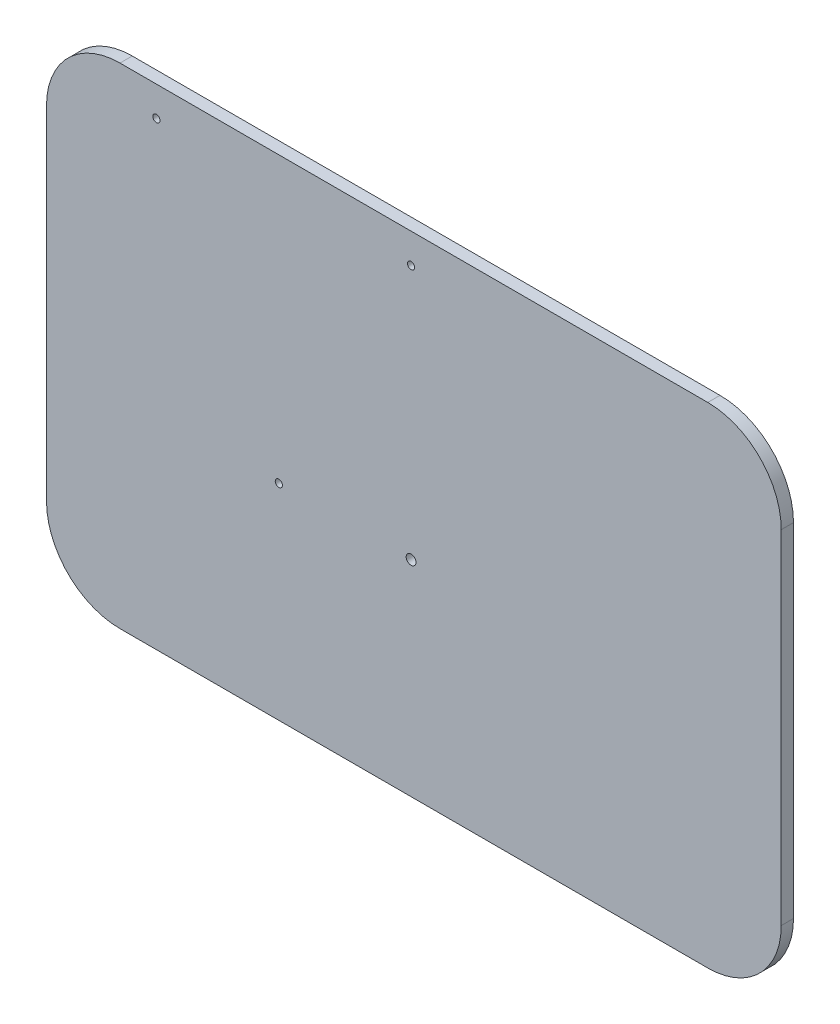
from build123d import *

# Parameters (mm, degrees)
SALIENTE_EXTRUIR1_DEPTH = 5
CROQUIS2_R              = 1.465459125
CROQUIS2_R_2            = 2
CORTAR_EXTRUIR1_DEPTH   = 5


with BuildPart() as part:
    # Croquis1 → Saliente-Extruir1 (new body)
    with BuildSketch(Plane.XY):
        with BuildLine():
            Line((30, 0), (270, 0))
            ThreePointArc((270, 0), (291.213203436, 8.786796564), (300, 30))
            Line((300, 30), (300, 170))
            ThreePointArc((300, 170), (291.213203436, 191.213203436), (270, 200))
            Line((270, 200), (30, 200))
            ThreePointArc((30, 200), (8.786796564, 191.213203436), (0, 170))
            Line((0, 170), (0, 30))
            ThreePointArc((0, 30), (8.786796564, 8.786796564), (30, 0))
        make_face()
    extrude(amount=SALIENTE_EXTRUIR1_DEPTH)

    # Croquis2 → Cortar-Extruir1 (cut)
    with BuildSketch(Plane(origin=(0, 0, 0), x_dir=(-1, 0, 0), z_dir=(0, 0, -1))):
        with Locations((-148.851699579, 187.841418575)):
            Circle(CROQUIS2_R)
        with Locations((-44.851699579, 187.841418575)):
            Circle(CROQUIS2_R)
        with Locations((-94.851699579, 83.841418575)):
            Circle(CROQUIS2_R)
        with Locations((-148.851699579, 83.841418575)):
            Circle(CROQUIS2_R_2)
    extrude(amount=-CORTAR_EXTRUIR1_DEPTH, mode=Mode.SUBTRACT)


solid = part.part
